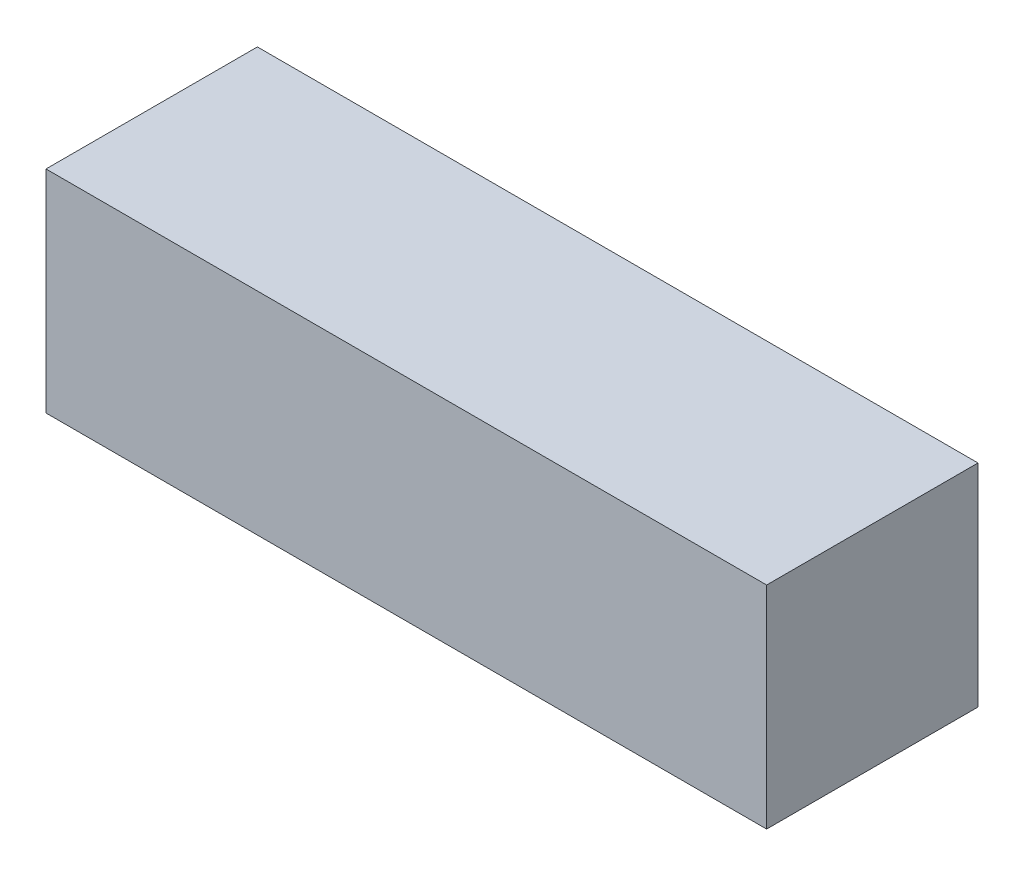
from build123d import *

# Parameters (mm, degrees)
SKETCH1_W           = 38.1
SKETCH1_H           = 11.176
BOSS_EXTRUDE1_DEPTH = 11.176


with BuildPart() as part:
    # Sketch1 → Boss-Extrude1 (new body)
    with BuildSketch(Plane(origin=(0, 0, 0), x_dir=(1, 0, 0), z_dir=(0, 1, 0))):
        with Locations((19.05, 5.588)):
            Rectangle(SKETCH1_W, SKETCH1_H)
    extrude(amount=BOSS_EXTRUDE1_DEPTH)


solid = part.part
